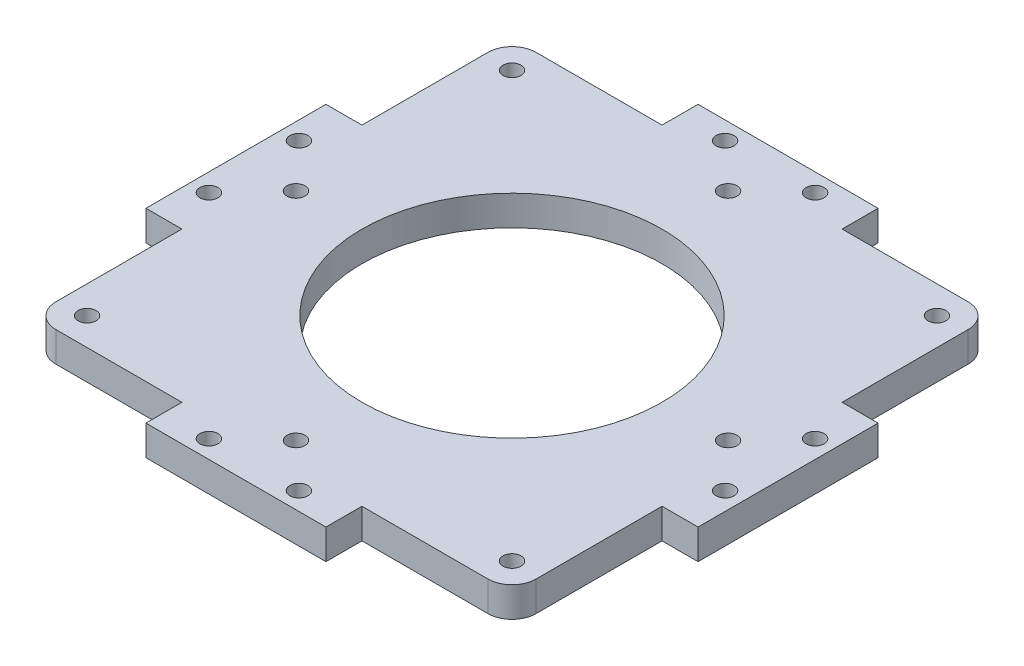
from build123d import *

# Parameters (mm, degrees)
SKETCH_1_W               = 80
SKETCH_1_H               = 80
SKETCH_1_R               = 25
EXTRUDE_1_DEPTH          = 5
SKETCH_3_R               = 1.5
CUT_EXTRUDE_2_DEPTH      = 5
PATTERN_CIRCULAR_1_COUNT = 4
FILLET_1_R               = 4
SKETCH_7_W               = 30
SKETCH_7_H               = 6
SKETCH_7_R               = 1.5
EXTRUDE_2_DEPTH          = 5
PATTERN_CIRCULAR_2_COUNT = 4


with BuildPart() as part:
    # 草图1 → 凸台-拉伸1 (new body)
    with BuildSketch(Plane(origin=(0, 0, 0), x_dir=(1, 0, 0), z_dir=(0, 1, 0))):
        Rectangle(SKETCH_1_W, SKETCH_1_H)
        Circle(SKETCH_1_R, mode=Mode.SUBTRACT)
    extrude(amount=EXTRUDE_1_DEPTH)

    # 草图3 → 切除-拉伸2 (cut)
    with BuildSketch(Plane(origin=(0, 0, 0), x_dir=(1, 0, 0), z_dir=(0, 1, 0))):
        with Locations((0, 36)):
            Circle(SKETCH_3_R)
        with Locations((-35.403805922, 35.403805922)):
            Circle(SKETCH_3_R)
    cut_extrude_2 = extrude(amount=CUT_EXTRUDE_2_DEPTH, mode=Mode.SUBTRACT)

    # 阵列(圆周)1: 切除-拉伸2 ×4 about axis
    pattern_circular_1_axis = Axis((0, 55, 0), (0, -1, 0))
    for i in range(1, PATTERN_CIRCULAR_1_COUNT):
        add(cut_extrude_2.rotate(pattern_circular_1_axis, i * 360 / PATTERN_CIRCULAR_1_COUNT), mode=Mode.SUBTRACT)

    # 圆角1
    fillet_1_edges = [part.edges().sort_by_distance(p)[0] for p in [
        (40, 2.5, 40),
        (40, 2.5, -40),
        (-40, 2.5, 40),
        (-40, 2.5, -40),
    ]]
    fillet(fillet_1_edges, radius=FILLET_1_R)

    # 草图7 → 凸台-拉伸2 (add)
    with BuildSketch(Plane(origin=(0, 0, 0), x_dir=(1, 0, 0), z_dir=(0, 1, 0))):
        with Locations((0, -43)):
            Rectangle(SKETCH_7_W, SKETCH_7_H)
        with Locations((-7.5, -43)):
            Circle(SKETCH_7_R, mode=Mode.SUBTRACT)
        with Locations((7.5, -43)):
            Circle(SKETCH_7_R, mode=Mode.SUBTRACT)
    extrude_2 = extrude(amount=EXTRUDE_2_DEPTH)

    # 阵列(圆周)2: 凸台-拉伸2 ×4 about axis
    pattern_circular_2_axis = Axis((0, 55, 0), (0, -1, 0))
    for i in range(1, PATTERN_CIRCULAR_2_COUNT):
        add(extrude_2.rotate(pattern_circular_2_axis, i * 360 / PATTERN_CIRCULAR_2_COUNT))


solid = part.part
